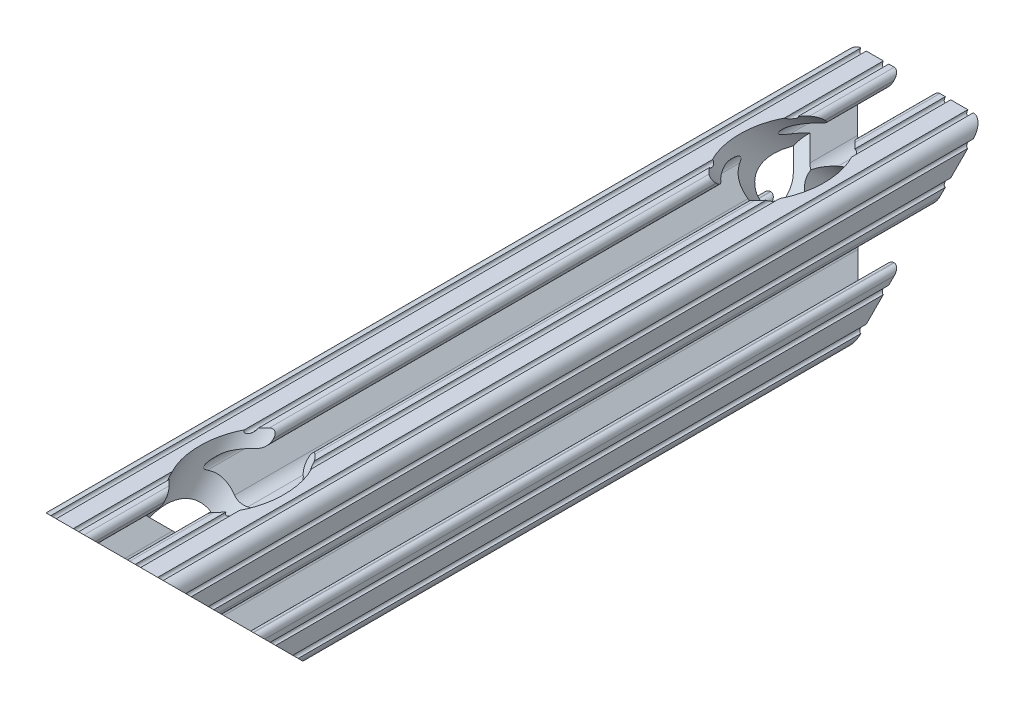
from build123d import *

# Parameters (mm, degrees)
SKETCH1_R               = 2.6035
BOSS_EXTRUDE1_DEPTH     = 76.2
CUT_EXTRUDE1_DEPTH      = 13.7
CUT_EXTRUDE1_DEPTH_BACK = 13.7


with BuildPart() as part:
    # Sketch1 → Boss-Extrude1 (new body, symmetric)
    with BuildSketch(Plane.XY):
        with BuildLine():
            Line((-7.179650497, -8.645192506), (-3.952270251, -5.423690499))
            ThreePointArc((-3.952270251, -5.423690499), (-2.922936451, -4.736929036), (-1.709253557, -4.4958))
            Line((-1.709253557, -4.4958), (1.709253557, -4.4958))
            ThreePointArc((1.709253557, -4.4958), (2.922936451, -4.736929036), (3.952270251, -5.423690499))
            Line((3.952270251, -5.423690499), (7.179650497, -8.645192506))
            ThreePointArc((7.179650497, -8.645192506), (7.41473083, -9.822813117), (6.416408329, -10.4902))
            Line((6.416408329, -10.4902), (4.287512407, -10.4902))
            ThreePointArc((4.287512407, -10.4902), (3.54574862, -10.79744862), (3.2385, -11.539212407))
            Line((3.2385, -11.539212407), (3.2385, -11.650987593))
            ThreePointArc((3.2385, -11.650987593), (3.54574862, -12.39275138), (4.287512407, -12.7))
            Line((4.287512407, -12.7), (5.317126718, -12.7))
            ThreePointArc((5.317126718, -12.7), (5.825126718, -12.192), (6.333126718, -12.7))
            Line((6.333126718, -12.7), (9.550443118, -12.7))
            ThreePointArc((9.550443118, -12.7), (10.058366869, -12.192000006), (10.566443095, -12.699847501))
            ThreePointArc((10.566443095, -12.699847501), (12.082537762, -12.08250727), (12.699846982, -10.566399977))
            ThreePointArc((12.699846982, -10.566399977), (12.192000006, -10.058323491), (12.7, -9.5504))
            Line((12.7, -9.5504), (12.7, -6.3330836))
            ThreePointArc((12.7, -6.3330836), (12.192, -5.8250836), (12.7, -5.3170836))
            Line((12.7, -5.3170836), (12.7, -4.287469289))
            ThreePointArc((12.7, -4.287469289), (12.39275138, -3.545705502), (11.650987593, -3.238456882))
            Line((11.650987593, -3.238456882), (11.539212407, -3.238456882))
            ThreePointArc((11.539212407, -3.238456882), (10.79744862, -3.545705502), (10.4902, -4.287469289))
            Line((10.4902, -4.287469289), (10.4902, -6.402089023))
            ThreePointArc((10.4902, -6.402089023), (9.856505071, -7.351067942), (8.737131347, -7.129408934))
            Line((8.737131347, -7.129408934), (5.441005833, -3.840816462))
            ThreePointArc((5.441005833, -3.840816462), (4.750877967, -2.809883091), (4.5085, -1.593185507))
            Line((4.5085, -1.593185507), (4.5085, 1.593185507))
            ThreePointArc((4.5085, 1.593185507), (4.750877967, 2.809883091), (5.441005833, 3.840816462))
            Line((5.441005833, 3.840816462), (8.737131347, 7.129408934))
            ThreePointArc((8.737131347, 7.129408934), (9.856505071, 7.351067942), (10.4902, 6.402089023))
            Line((10.4902, 6.402089023), (10.4902, 4.287469289))
            ThreePointArc((10.4902, 4.287469289), (10.79744862, 3.545705502), (11.539212407, 3.238456882))
            Line((11.539212407, 3.238456882), (11.650987593, 3.238456882))
            ThreePointArc((11.650987593, 3.238456882), (12.39275138, 3.545705502), (12.7, 4.287469289))
            Line((12.7, 4.287469289), (12.7, 5.3170836))
            ThreePointArc((12.7, 5.3170836), (12.192, 5.8250836), (12.7, 6.3330836))
            Line((12.7, 6.3330836), (12.7, 9.5504))
            ThreePointArc((12.7, 9.5504), (12.192000006, 10.058323491), (12.699846982, 10.566399977))
            ThreePointArc((12.699846982, 10.566399977), (12.082537762, 12.08250727), (10.566443095, 12.699847501))
            ThreePointArc((10.566443095, 12.699847501), (10.058366869, 12.192000006), (9.550443118, 12.7))
            Line((9.550443118, 12.7), (6.333126718, 12.7))
            ThreePointArc((6.333126718, 12.7), (5.825126718, 12.192), (5.317126718, 12.7))
            Line((5.317126718, 12.7), (4.287512407, 12.7))
            ThreePointArc((4.287512407, 12.7), (3.54574862, 12.39275138), (3.2385, 11.650987593))
            Line((3.2385, 11.650987593), (3.2385, 11.539212407))
            ThreePointArc((3.2385, 11.539212407), (3.54574862, 10.79744862), (4.287512407, 10.4902))
            Line((4.287512407, 10.4902), (6.476788598, 10.4902))
            ThreePointArc((6.476788598, 10.4902), (7.432222385, 9.85140422), (7.207036008, 8.724370562))
            Line((7.207036008, 8.724370562), (3.898272566, 5.423169045))
            ThreePointArc((3.898272566, 5.423169045), (2.869120213, 4.736787962), (1.655778399, 4.4958))
            Line((1.655778399, 4.4958), (-1.655778399, 4.4958))
            ThreePointArc((-1.655778399, 4.4958), (-2.869120213, 4.736787962), (-3.898272566, 5.423169045))
            Line((-3.898272566, 5.423169045), (-7.207036008, 8.724370562))
            ThreePointArc((-7.207036008, 8.724370562), (-7.432222385, 9.85140422), (-6.476788598, 10.4902))
            Line((-6.476788598, 10.4902), (-4.287512407, 10.4902))
            ThreePointArc((-4.287512407, 10.4902), (-3.54574862, 10.79744862), (-3.2385, 11.539212407))
            Line((-3.2385, 11.539212407), (-3.2385, 11.650987593))
            ThreePointArc((-3.2385, 11.650987593), (-3.54574862, 12.39275138), (-4.287512407, 12.7))
            Line((-4.287512407, 12.7), (-5.317126718, 12.7))
            ThreePointArc((-5.317126718, 12.7), (-5.825126718, 12.192), (-6.333126718, 12.7))
            Line((-6.333126718, 12.7), (-9.550443118, 12.7))
            ThreePointArc((-9.550443118, 12.7), (-10.058366869, 12.192000006), (-10.566443095, 12.699847501))
            ThreePointArc((-10.566443095, 12.699847501), (-12.082537762, 12.08250727), (-12.699846982, 10.566399977))
            ThreePointArc((-12.699846982, 10.566399977), (-12.192000006, 10.058323491), (-12.7, 9.5504))
            Line((-12.7, 9.5504), (-12.7, 6.3330836))
            ThreePointArc((-12.7, 6.3330836), (-12.192, 5.8250836), (-12.7, 5.3170836))
            Line((-12.7, 5.3170836), (-12.7, 4.287469289))
            ThreePointArc((-12.7, 4.287469289), (-12.39275138, 3.545705502), (-11.650987593, 3.238456882))
            Line((-11.650987593, 3.238456882), (-11.539212407, 3.238456882))
            ThreePointArc((-11.539212407, 3.238456882), (-10.79744862, 3.545705502), (-10.4902, 4.287469289))
            Line((-10.4902, 4.287469289), (-10.4902, 6.402089023))
            ThreePointArc((-10.4902, 6.402089023), (-9.856505071, 7.351067942), (-8.737131347, 7.129408934))
            Line((-8.737131347, 7.129408934), (-5.441005833, 3.840816462))
            ThreePointArc((-5.441005833, 3.840816462), (-4.750877967, 2.809883091), (-4.5085, 1.593185507))
            Line((-4.5085, 1.593185507), (-4.5085, -1.593185507))
            ThreePointArc((-4.5085, -1.593185507), (-4.750877967, -2.809883091), (-5.441005833, -3.840816462))
            Line((-5.441005833, -3.840816462), (-8.737131347, -7.129408934))
            ThreePointArc((-8.737131347, -7.129408934), (-9.856505071, -7.351067942), (-10.4902, -6.402089023))
            Line((-10.4902, -6.402089023), (-10.4902, -4.287469289))
            ThreePointArc((-10.4902, -4.287469289), (-10.79744862, -3.545705502), (-11.539212407, -3.238456882))
            Line((-11.539212407, -3.238456882), (-11.650987593, -3.238456882))
            ThreePointArc((-11.650987593, -3.238456882), (-12.39275138, -3.545705502), (-12.7, -4.287469289))
            Line((-12.7, -4.287469289), (-12.7, -5.3170836))
            ThreePointArc((-12.7, -5.3170836), (-12.192, -5.8250836), (-12.7, -6.3330836))
            Line((-12.7, -6.3330836), (-12.7, -9.5504))
            ThreePointArc((-12.7, -9.5504), (-12.192000006, -10.058323491), (-12.699846982, -10.566399977))
            ThreePointArc((-12.699846982, -10.566399977), (-12.082537762, -12.08250727), (-10.566443095, -12.699847501))
            ThreePointArc((-10.566443095, -12.699847501), (-10.058366869, -12.192000006), (-9.550443118, -12.7))
            Line((-9.550443118, -12.7), (-6.333126718, -12.7))
            ThreePointArc((-6.333126718, -12.7), (-5.825126718, -12.192), (-5.317126718, -12.7))
            Line((-5.317126718, -12.7), (-4.287512407, -12.7))
            ThreePointArc((-4.287512407, -12.7), (-3.54574862, -12.39275138), (-3.2385, -11.650987593))
            Line((-3.2385, -11.650987593), (-3.2385, -11.539212407))
            ThreePointArc((-3.2385, -11.539212407), (-3.54574862, -10.79744862), (-4.287512407, -10.4902))
            Line((-4.287512407, -10.4902), (-6.416408329, -10.4902))
            ThreePointArc((-6.416408329, -10.4902), (-7.41473083, -9.822813117), (-7.179650497, -8.645192506))
        make_face()
        Circle(SKETCH1_R, mode=Mode.SUBTRACT)
    extrude(amount=BOSS_EXTRUDE1_DEPTH, both=True)

    # Sketch2 → Cut-Extrude1 (cut, two sides)
    with BuildSketch(Plane(origin=(0, 0, 0), x_dir=(0, 0, -1), z_dir=(1, 0, 0))) as cut_extrude1_sk:
        Polygon((-76.2, 12.699847501), (-76.2, -12.7), (-50.800152499, -12.7), align=None)
        Polygon((50.800152499, -12.7), (76.2, 12.699847501), (76.2, -12.7), align=None)
    extrude(amount=CUT_EXTRUDE1_DEPTH, mode=Mode.SUBTRACT)
    extrude(cut_extrude1_sk.sketch, amount=-CUT_EXTRUDE1_DEPTH_BACK, mode=Mode.SUBTRACT)

    # Sketch3 → Cut-Revolve1 (revolve, cut)
    with BuildSketch(Plane(origin=(0, 0, 0), x_dir=(0, 0, -1), z_dir=(1, 0, 0))):
        Polygon((-45.187644922, 18.312507577), (-63.500152499, 0), (-65.808078322, 2.307925823), (-61.317950261, 6.798053884), (-64.622684514, 10.102788136), (-50.800304998, 23.925167653), align=None)
    cut_revolve1 = revolve(axis=Axis((0, 0, 63.500152499), (0, -0.707106781, 0.707106781)), mode=Mode.SUBTRACT)

    # Mirror1: Cut-Revolve1 across plane
    add(cut_revolve1.mirror(Plane.XY), mode=Mode.SUBTRACT)


solid = part.part
